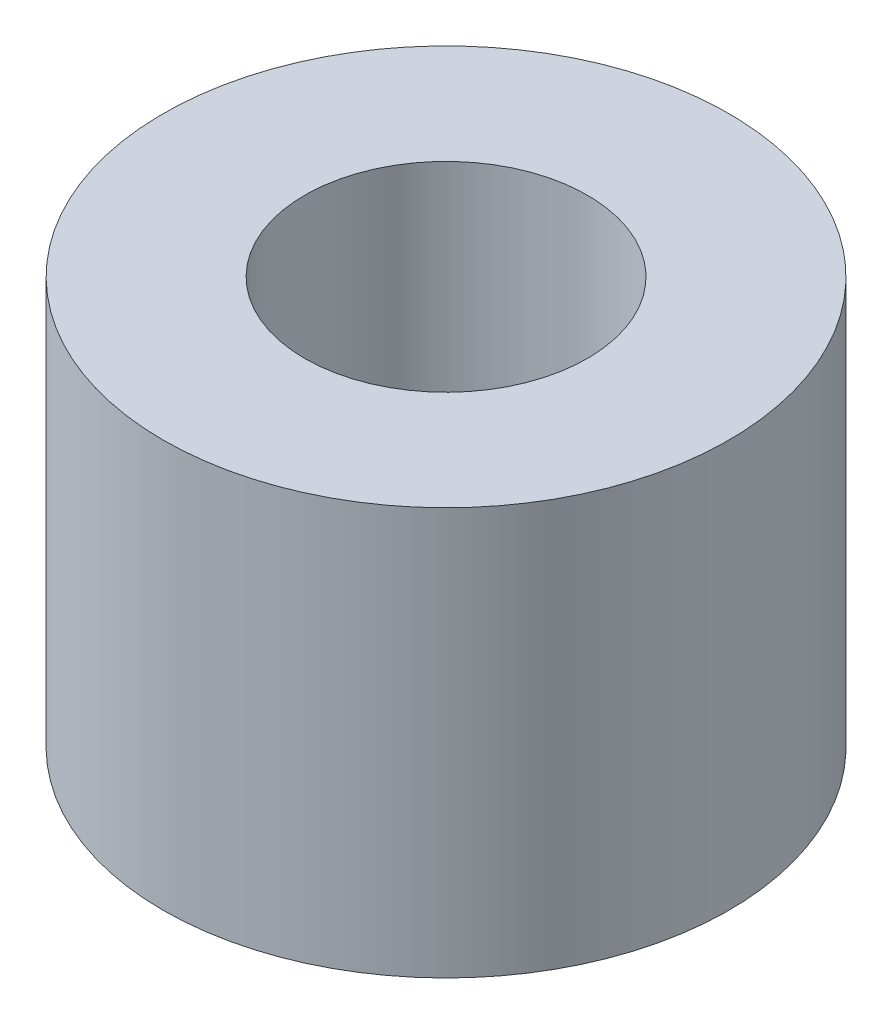
from build123d import *

# Parameters (mm, degrees)
SKETCH1_R           = 23
SKETCH1_R_2         = 11.5
BOSS_EXTRUDE1_DEPTH = 33.12


with BuildPart() as part:
    # Sketch1 → Boss-Extrude1 (new body)
    with BuildSketch(Plane(origin=(0, 0, 0), x_dir=(1, 0, 0), z_dir=(0, 1, 0))):
        Circle(SKETCH1_R)
        Circle(SKETCH1_R_2, mode=Mode.SUBTRACT)
    extrude(amount=BOSS_EXTRUDE1_DEPTH)


solid = part.part
